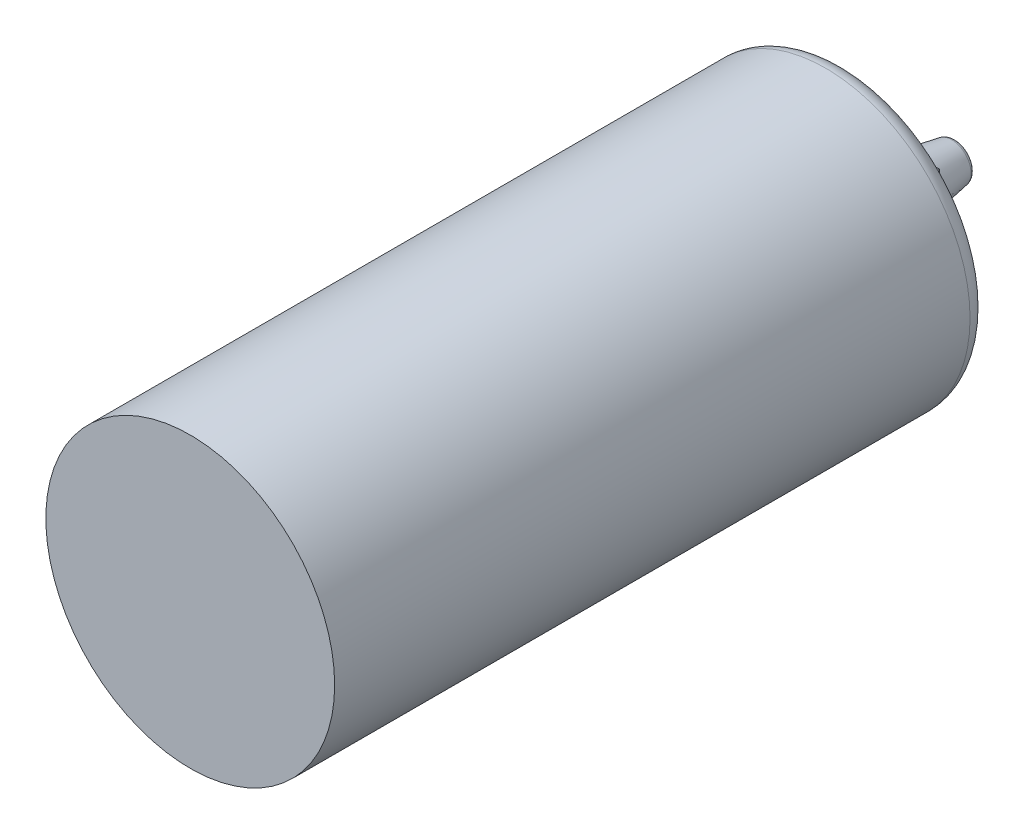
from build123d import *

# Parameters (mm, degrees)
SKETCH1_R                     = 19.05
BOSS_EXTRUDE1_DEPTH           = 86.36
SKETCH2_W                     = 22.86
SKETCH2_H                     = 22.86
BOSS_EXTRUDE2_DEPTH           = 1.27
BOSS_EXTRUDE2_TAPER           = 10
FILLET1_R                     = 2.54
SKETCH3_R                     = 3.81
BOSS_EXTRUDE3_DEPTH           = 7.62
BOSS_EXTRUDE3_DRAFT           = 10
BOSS_EXTRUDE3_PROFILE_2_DEPTH = 7.62
BOSS_EXTRUDE3_PROFILE_2_DRAFT = 10
BOSS_EXTRUDE3_PROFILE_3_DEPTH = 7.62
BOSS_EXTRUDE3_PROFILE_3_DRAFT = 10
BOSS_EXTRUDE3_PROFILE_4_DEPTH = 7.62
BOSS_EXTRUDE3_PROFILE_4_DRAFT = 10
FILLET2_R                     = 0.635


with BuildPart() as part:
    # Sketch1 → Boss-Extrude1 (new body)
    with BuildSketch(Plane.XY):
        Circle(SKETCH1_R)
    extrude(amount=BOSS_EXTRUDE1_DEPTH)

    # Sketch2 → Boss-Extrude2 (add)
    with BuildSketch(Plane(origin=(0, 0, 0), x_dir=(-1, 0, 0), z_dir=(0, 0, -1))):
        Rectangle(SKETCH2_W, SKETCH2_H)
    extrude(amount=BOSS_EXTRUDE2_DEPTH, taper=BOSS_EXTRUDE2_TAPER)

    # Fillet1
    fillet1_edges = [part.edges().sort_by_distance(p)[0] for p in [
        (-19.05, 0, 0),
    ]]
    fillet(fillet1_edges, radius=FILLET1_R)


with BuildPart() as boss_extrude3_tool:
    # Sketch3 → Boss-Extrude3 (with draft: the straight prism first)
    with BuildSketch(Plane(origin=(0, 0, -1.27), x_dir=(-1, 0, 0), z_dir=(0, 0, -1))):
        with Locations((-5.715, 5.715)):
            Circle(SKETCH3_R)
    extrude(amount=BOSS_EXTRUDE3_DEPTH)
    # Boss-Extrude3: the draft: its side faces are tilted about the plane it starts from
    boss_extrude3_sides = [boss_extrude3_tool.faces().sort_by_distance(p)[0] for p in [
        (9.525, 5.715, -5.08),
    ]]
    draft(boss_extrude3_sides, Plane(origin=(0, 0, -1.27), x_dir=(-1, 0, 0), z_dir=(0, 0, -1)), BOSS_EXTRUDE3_DRAFT)


with BuildPart() as part_1:
    add(part.part)

    # Boss-Extrude3: add boss_extrude3_tool
    add(boss_extrude3_tool.part)


with BuildPart() as boss_extrude3_profile_2_tool:
    # Sketch3 → Boss-Extrude3 profile 2 (with draft: the straight prism first)
    with BuildSketch(Plane(origin=(0, 0, -1.27), x_dir=(-1, 0, 0), z_dir=(0, 0, -1))):
        with Locations((5.715, 5.715)):
            Circle(SKETCH3_R)
    extrude(amount=BOSS_EXTRUDE3_PROFILE_2_DEPTH)
    # Boss-Extrude3 profile 2: the draft: its side faces are tilted about the plane it starts from
    boss_extrude3_profile_2_sides = [boss_extrude3_profile_2_tool.faces().sort_by_distance(p)[0] for p in [
        (-1.905, 5.715, -5.08),
    ]]
    draft(boss_extrude3_profile_2_sides, Plane(origin=(0, 0, -1.27), x_dir=(-1, 0, 0), z_dir=(0, 0, -1)), BOSS_EXTRUDE3_PROFILE_2_DRAFT)


with BuildPart() as part_2:
    add(part_1.part)

    # Boss-Extrude3 profile 2: add boss_extrude3_profile_2_tool
    add(boss_extrude3_profile_2_tool.part)


with BuildPart() as boss_extrude3_profile_3_tool:
    # Sketch3 → Boss-Extrude3 profile 3 (with draft: the straight prism first)
    with BuildSketch(Plane(origin=(0, 0, -1.27), x_dir=(-1, 0, 0), z_dir=(0, 0, -1))):
        with Locations((-5.715, -5.715)):
            Circle(SKETCH3_R)
    extrude(amount=BOSS_EXTRUDE3_PROFILE_3_DEPTH)
    # Boss-Extrude3 profile 3: the draft: its side faces are tilted about the plane it starts from
    boss_extrude3_profile_3_sides = [boss_extrude3_profile_3_tool.faces().sort_by_distance(p)[0] for p in [
        (9.525, -5.715, -5.08),
    ]]
    draft(boss_extrude3_profile_3_sides, Plane(origin=(0, 0, -1.27), x_dir=(-1, 0, 0), z_dir=(0, 0, -1)), BOSS_EXTRUDE3_PROFILE_3_DRAFT)


with BuildPart() as part_3:
    add(part_2.part)

    # Boss-Extrude3 profile 3: add boss_extrude3_profile_3_tool
    add(boss_extrude3_profile_3_tool.part)


with BuildPart() as boss_extrude3_profile_4_tool:
    # Sketch3 → Boss-Extrude3 profile 4 (with draft: the straight prism first)
    with BuildSketch(Plane(origin=(0, 0, -1.27), x_dir=(-1, 0, 0), z_dir=(0, 0, -1))):
        with Locations((5.715, -5.715)):
            Circle(SKETCH3_R)
    extrude(amount=BOSS_EXTRUDE3_PROFILE_4_DEPTH)
    # Boss-Extrude3 profile 4: the draft: its side faces are tilted about the plane it starts from
    boss_extrude3_profile_4_sides = [boss_extrude3_profile_4_tool.faces().sort_by_distance(p)[0] for p in [
        (-1.905, -5.715, -5.08),
    ]]
    draft(boss_extrude3_profile_4_sides, Plane(origin=(0, 0, -1.27), x_dir=(-1, 0, 0), z_dir=(0, 0, -1)), BOSS_EXTRUDE3_PROFILE_4_DRAFT)


with BuildPart() as part_4:
    add(part_3.part)

    # Boss-Extrude3 profile 4: add boss_extrude3_profile_4_tool
    add(boss_extrude3_profile_4_tool.part)

    # Fillet2
    fillet2_edges = [part_4.edges().sort_by_distance(p)[0] for p in [
        (8.181388407, 5.715, -8.89),
        (-3.248611593, 5.715, -8.89),
        (8.181388407, -5.715, -8.89),
        (-3.248611593, -5.715, -8.89),
    ]]
    fillet(fillet2_edges, radius=FILLET2_R)

    # Cut-Extrude1 cone 1 section (through the dimple's axis) → Cut-Extrude1 (revolve, cut)
    with BuildSketch(Plane(origin=(5.715, 5.715, -8.89), x_dir=(0, 1, 0), z_dir=(1, 0, 0))):
        Polygon((0, 0), (1.27, 0), (0, 14.516166425), align=None)
    revolve(axis=Axis((5.715, 5.715, -8.89), (0, 0, 1)), mode=Mode.SUBTRACT)

    # Cut-Extrude1 cone 2 section (through the dimple's axis) → Cut-Extrude1 cone 2 (revolve, cut)
    with BuildSketch(Plane(origin=(-5.715, 5.715, -8.89), x_dir=(0, 1, 0), z_dir=(1, 0, 0))):
        Polygon((0, 0), (1.27, 0), (0, 14.516166425), align=None)
    revolve(axis=Axis((-5.715, 5.715, -8.89), (0, 0, 1)), mode=Mode.SUBTRACT)

    # Cut-Extrude1 cone 3 section (through the dimple's axis) → Cut-Extrude1 cone 3 (revolve, cut)
    with BuildSketch(Plane(origin=(-5.715, -5.715, -8.89), x_dir=(0, 1, 0), z_dir=(1, 0, 0))):
        Polygon((0, 0), (1.27, 0), (0, 14.516166425), align=None)
    revolve(axis=Axis((-5.715, -5.715, -8.89), (0, 0, 1)), mode=Mode.SUBTRACT)

    # Cut-Extrude1 cone 4 section (through the dimple's axis) → Cut-Extrude1 cone 4 (revolve, cut)
    with BuildSketch(Plane(origin=(5.715, -5.715, -8.89), x_dir=(0, 1, 0), z_dir=(1, 0, 0))):
        Polygon((0, 0), (1.27, 0), (0, 14.516166425), align=None)
    revolve(axis=Axis((5.715, -5.715, -8.89), (0, 0, 1)), mode=Mode.SUBTRACT)


solid = part_4.part
